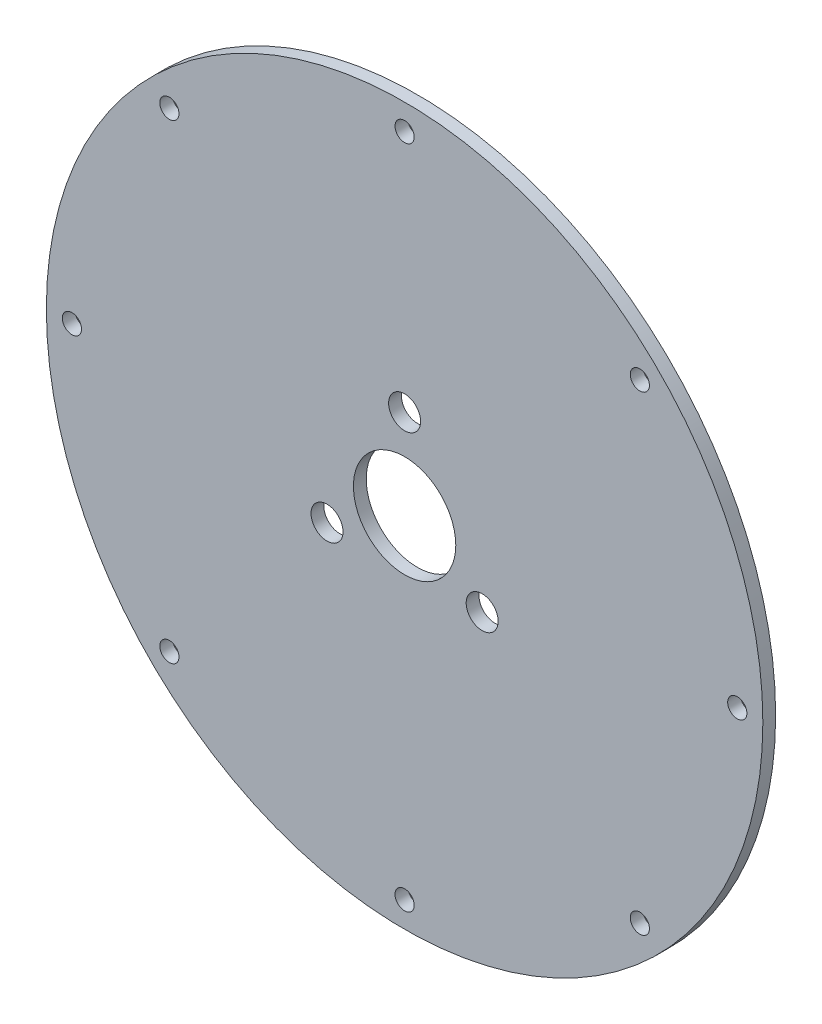
from build123d import *

# Parameters (mm, degrees)
SKETCH1_R           = 88.9
SKETCH1_R_2         = 3.96875
SKETCH1_R_3         = 2.38125
SKETCH1_R_4         = 12.7
BOSS_EXTRUDE1_DEPTH = 3.175


with BuildPart() as part:
    # Sketch1 → Boss-Extrude1 (new body)
    with BuildSketch(Plane.XY):
        Circle(SKETCH1_R)
        with Locations((0, 22.225)):
            Circle(SKETCH1_R_2, mode=Mode.SUBTRACT)
        with Locations((19.247414599, -11.1125)):
            Circle(SKETCH1_R_2, mode=Mode.SUBTRACT)
        with Locations((-19.247414599, -11.1125)):
            Circle(SKETCH1_R_2, mode=Mode.SUBTRACT)
        with Locations((0, 82.55)):
            Circle(SKETCH1_R_3, mode=Mode.SUBTRACT)
        with Locations((58.371664787, 58.371664787)):
            Circle(SKETCH1_R_3, mode=Mode.SUBTRACT)
        with Locations((82.55, 0)):
            Circle(SKETCH1_R_3, mode=Mode.SUBTRACT)
        with Locations((58.371664787, -58.371664787)):
            Circle(SKETCH1_R_3, mode=Mode.SUBTRACT)
        with Locations((0, -82.55)):
            Circle(SKETCH1_R_3, mode=Mode.SUBTRACT)
        with Locations((-58.371664787, -58.371664787)):
            Circle(SKETCH1_R_3, mode=Mode.SUBTRACT)
        with Locations((-82.55, 0)):
            Circle(SKETCH1_R_3, mode=Mode.SUBTRACT)
        with Locations((-58.371664787, 58.371664787)):
            Circle(SKETCH1_R_3, mode=Mode.SUBTRACT)
        Circle(SKETCH1_R_4, mode=Mode.SUBTRACT)
    extrude(amount=BOSS_EXTRUDE1_DEPTH)


solid = part.part
